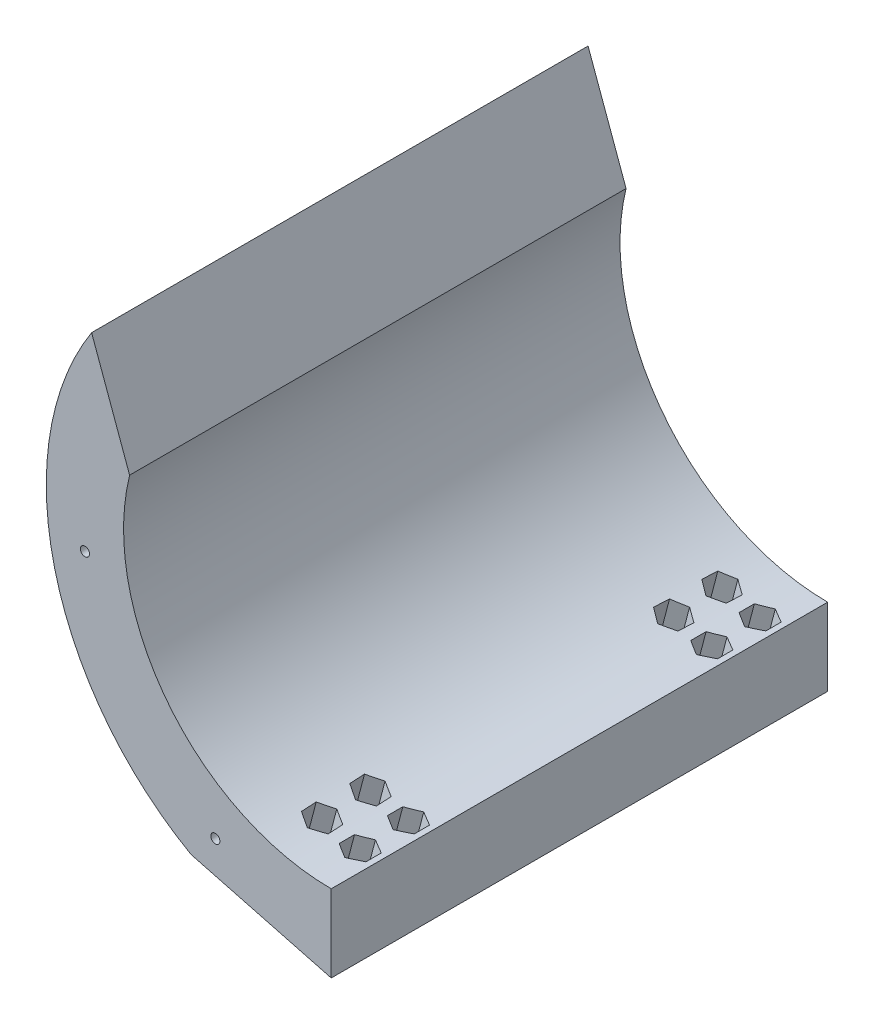
from build123d import *

# Parameters (mm, degrees)
BOSS_EXTRUDE1_DEPTH = 102.8
CUT_EXTRUDE1_DEPTH  = 103.8
CUT_EXTRUDE2_DEPTH  = 103.8
CUT_EXTRUDE3_REACH  = 89.934
SKETCH5_R           = 1.65
CUT_EXTRUDE4_START  = -5
CUT_EXTRUDE4_DEPTH  = 83.934228689
SKETCH7_R           = 0.95
CUT_EXTRUDE5_DEPTH  = 103.8


with BuildPart() as part:
    # Sketch1 → Boss-Extrude1 (new body)
    with BuildSketch(Plane.XY):
        with BuildLine():
            Line((0, 59), (0, 43))
            ThreePointArc((0, 43), (-43, 0), (0, -43))
            Line((0, -43), (0, -59))
            ThreePointArc((0, -59), (-59, 0), (0, 59))
        make_face()
    extrude(amount=BOSS_EXTRUDE1_DEPTH)

    # Sketch3 → Cut-Extrude1 (cut, through all)
    with BuildSketch(Plane.XY.offset(102.8)):
        Polygon((0, 0), (0, 90), (-70.757321084, 90), (-38, 0), align=None)
    extrude(amount=-CUT_EXTRUDE1_DEPTH, mode=Mode.SUBTRACT)

    # Sketch4 → Cut-Extrude2 (cut, through all)
    with BuildSketch(Plane.XY.offset(102.8)):
        Polygon((0, -59), (-29.014256172, -51.372881356), (-31.019233948, -59), align=None)
    extrude(amount=-CUT_EXTRUDE2_DEPTH, mode=Mode.SUBTRACT)

    # Sketch5 → Cut-Extrude3 (cut, up to next)
    with BuildSketch(Plane(origin=(-14.507128086, -55.186440678, 0), x_dir=(0.967141872, -0.254237288, 0), z_dir=(-0.254237288, -0.967141872, 0)), mode=Mode.PRIVATE) as cut_extrude3_sk1:
        with Locations((-1, 20)):
            Circle(SKETCH5_R)
    cut_extrude3_tool1 = extrude(cut_extrude3_sk1.sketch, amount=-CUT_EXTRUDE3_REACH, mode=Mode.PRIVATE) & part.part
    add(cut_extrude3_tool1.solids().sort_by_distance((-15.47427, -54.932203, 20))[0], mode=Mode.SUBTRACT)
    # Sketch5 → Cut-Extrude3 (cut, up to next)
    with BuildSketch(Plane(origin=(-14.507128086, -55.186440678, 0), x_dir=(0.967141872, -0.254237288, 0), z_dir=(-0.254237288, -0.967141872, 0)), mode=Mode.PRIVATE) as cut_extrude3_sk2:
        with Locations((-1, 10)):
            Circle(SKETCH5_R)
    cut_extrude3_tool2 = extrude(cut_extrude3_sk2.sketch, amount=-CUT_EXTRUDE3_REACH, mode=Mode.PRIVATE) & part.part
    add(cut_extrude3_tool2.solids().sort_by_distance((-15.47427, -54.932203, 10))[0], mode=Mode.SUBTRACT)
    # Sketch5 → Cut-Extrude3 (cut, up to next)
    with BuildSketch(Plane(origin=(-14.507128086, -55.186440678, 0), x_dir=(0.967141872, -0.254237288, 0), z_dir=(-0.254237288, -0.967141872, 0)), mode=Mode.PRIVATE) as cut_extrude3_sk3:
        with Locations((-1, 92.8)):
            Circle(SKETCH5_R)
    cut_extrude3_tool3 = extrude(cut_extrude3_sk3.sketch, amount=-CUT_EXTRUDE3_REACH, mode=Mode.PRIVATE) & part.part
    add(cut_extrude3_tool3.solids().sort_by_distance((-15.47427, -54.932203, 92.8))[0], mode=Mode.SUBTRACT)
    # Sketch5 → Cut-Extrude3 (cut, up to next)
    with BuildSketch(Plane(origin=(-14.507128086, -55.186440678, 0), x_dir=(0.967141872, -0.254237288, 0), z_dir=(-0.254237288, -0.967141872, 0)), mode=Mode.PRIVATE) as cut_extrude3_sk4:
        with Locations((-1, 82.8)):
            Circle(SKETCH5_R)
    cut_extrude3_tool4 = extrude(cut_extrude3_sk4.sketch, amount=-CUT_EXTRUDE3_REACH, mode=Mode.PRIVATE) & part.part
    add(cut_extrude3_tool4.solids().sort_by_distance((-15.47427, -54.932203, 82.8))[0], mode=Mode.SUBTRACT)
    # Sketch5 → Cut-Extrude3 (cut, up to next)
    with BuildSketch(Plane(origin=(-14.507128086, -55.186440678, 0), x_dir=(0.967141872, -0.254237288, 0), z_dir=(-0.254237288, -0.967141872, 0)), mode=Mode.PRIVATE) as cut_extrude3_sk5:
        with Locations((7, 20)):
            Circle(SKETCH5_R)
    cut_extrude3_tool5 = extrude(cut_extrude3_sk5.sketch, amount=-CUT_EXTRUDE3_REACH, mode=Mode.PRIVATE) & part.part
    add(cut_extrude3_tool5.solids().sort_by_distance((-7.737135, -56.966102, 20))[0], mode=Mode.SUBTRACT)
    # Sketch5 → Cut-Extrude3 (cut, up to next)
    with BuildSketch(Plane(origin=(-14.507128086, -55.186440678, 0), x_dir=(0.967141872, -0.254237288, 0), z_dir=(-0.254237288, -0.967141872, 0)), mode=Mode.PRIVATE) as cut_extrude3_sk6:
        with Locations((7, 10)):
            Circle(SKETCH5_R)
    cut_extrude3_tool6 = extrude(cut_extrude3_sk6.sketch, amount=-CUT_EXTRUDE3_REACH, mode=Mode.PRIVATE) & part.part
    add(cut_extrude3_tool6.solids().sort_by_distance((-7.737135, -56.966102, 10))[0], mode=Mode.SUBTRACT)
    # Sketch5 → Cut-Extrude3 (cut, up to next)
    with BuildSketch(Plane(origin=(-14.507128086, -55.186440678, 0), x_dir=(0.967141872, -0.254237288, 0), z_dir=(-0.254237288, -0.967141872, 0)), mode=Mode.PRIVATE) as cut_extrude3_sk7:
        with Locations((7, 92.8)):
            Circle(SKETCH5_R)
    cut_extrude3_tool7 = extrude(cut_extrude3_sk7.sketch, amount=-CUT_EXTRUDE3_REACH, mode=Mode.PRIVATE) & part.part
    add(cut_extrude3_tool7.solids().sort_by_distance((-7.737135, -56.966102, 92.8))[0], mode=Mode.SUBTRACT)
    # Sketch5 → Cut-Extrude3 (cut, up to next)
    with BuildSketch(Plane(origin=(-14.507128086, -55.186440678, 0), x_dir=(0.967141872, -0.254237288, 0), z_dir=(-0.254237288, -0.967141872, 0)), mode=Mode.PRIVATE) as cut_extrude3_sk8:
        with Locations((7, 82.8)):
            Circle(SKETCH5_R)
    cut_extrude3_tool8 = extrude(cut_extrude3_sk8.sketch, amount=-CUT_EXTRUDE3_REACH, mode=Mode.PRIVATE) & part.part
    add(cut_extrude3_tool8.solids().sort_by_distance((-7.737135, -56.966102, 82.8))[0], mode=Mode.SUBTRACT)

    # Sketch6 → Cut-Extrude4 (cut, through all)
    with BuildSketch(Plane(origin=(-14.507128086, -55.186440678, 0), x_dir=(0.967141872, -0.254237288, 0), z_dir=(-0.254237288, -0.967141872, 0)).offset(CUT_EXTRUDE4_START)):
        Polygon((7, 95.972596752), (4.252450617, 94.386298376), (4.252450617, 91.213701624), (7, 89.627403248), (9.747549383, 91.213701624), (9.747549383, 94.386298376), align=None)
        Polygon((1.680535984, 91.097631011), (1.814562783, 94.270227763), (-0.865973201, 95.972596752), (-3.680535984, 94.502368989), (-3.814562783, 91.329772237), (-1.134026799, 89.627403248), align=None)
        Polygon((1.680535984, 81.097631011), (1.814562783, 84.270227763), (-0.865973201, 85.972596752), (-3.680535984, 84.502368989), (-3.814562783, 81.329772237), (-1.134026799, 79.627403248), align=None)
        Polygon((1.680535984, 21.702368989), (-1.134026799, 23.172596752), (-3.814562783, 21.470227763), (-3.680535984, 18.297631011), (-0.865973201, 16.827403248), (1.814562783, 18.529772237), align=None)
        Polygon((1.680535984, 11.702368989), (-1.134026799, 13.172596752), (-3.814562783, 11.470227763), (-3.680535984, 8.297631011), (-0.865973201, 6.827403248), (1.814562783, 8.529772237), align=None)
        Polygon((7, 85.972596752), (4.252450617, 84.386298376), (4.252450617, 81.213701624), (7, 79.627403248), (9.747549383, 81.213701624), (9.747549383, 84.386298376), align=None)
        Polygon((7, 23.172596752), (4.252450617, 21.586298376), (4.252450617, 18.413701624), (7, 16.827403248), (9.747549383, 18.413701624), (9.747549383, 21.586298376), align=None)
        Polygon((7, 13.172596752), (4.252450617, 11.586298376), (4.252450617, 8.413701624), (7, 6.827403248), (9.747549383, 8.413701624), (9.747549383, 11.586298376), align=None)
    extrude(amount=-CUT_EXTRUDE4_DEPTH, mode=Mode.SUBTRACT)

    # Sketch7 → Cut-Extrude5 (cut, through all)
    with BuildSketch(Plane(origin=(0, 0, 0), x_dir=(-1, 0, 0), z_dir=(0, 0, -1))):
        with Locations((24, -46)):
            Circle(SKETCH7_R)
        with Locations((51, -8)):
            Circle(SKETCH7_R)
    extrude(amount=-CUT_EXTRUDE5_DEPTH, mode=Mode.SUBTRACT)


solid = part.part
